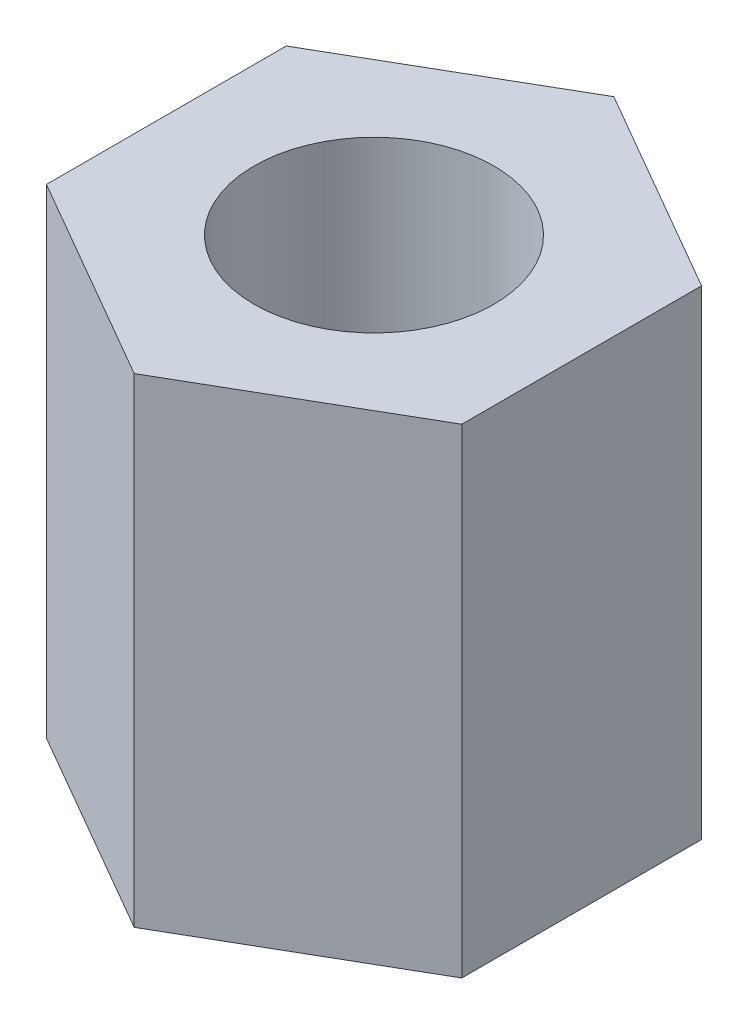
from build123d import *

# Parameters (mm, degrees)
ESQUISSE1_R      = 2.5
EXTRUSION1_DEPTH = 10


with BuildPart() as part:
    # Esquisse1 → Extrusion1 (new body)
    with BuildSketch(Plane(origin=(0, 0, 0), x_dir=(1, 0, 0), z_dir=(0, 1, 0))):
        Polygon((0, 5), (-4.330127019, 2.5), (-4.330127019, -2.5), (0, -5), (4.330127019, -2.5), (4.330127019, 2.5), align=None)
        Circle(ESQUISSE1_R, mode=Mode.SUBTRACT)
    extrude(amount=EXTRUSION1_DEPTH)


solid = part.part
